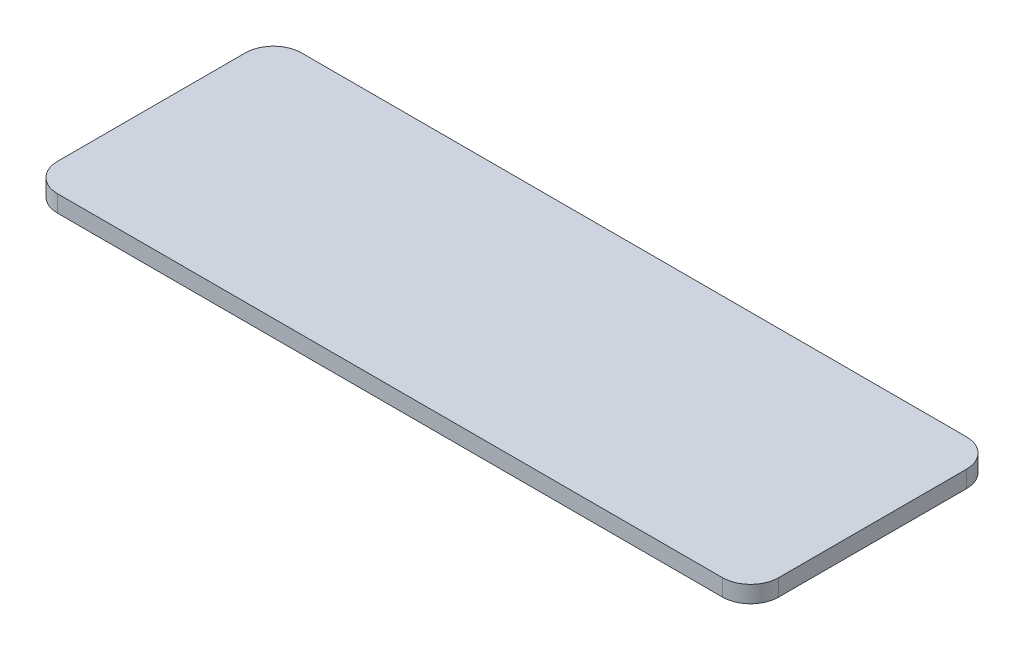
from build123d import *

# Parameters (mm, degrees)
SKETCH2_W           = 256.44751275
SKETCH2_H           = 86.763856324
BOSS_EXTRUDE2_DEPTH = 6
FILLET1_R           = 10


with BuildPart() as part:
    # Sketch2 → Boss-Extrude2 (new body)
    with BuildSketch(Plane(origin=(0, 0, 0), x_dir=(1, 0, 0), z_dir=(0, 1, 0))):
        with Locations((-92.975357556, 78.4180884)):
            Rectangle(SKETCH2_W, SKETCH2_H)
    extrude(amount=BOSS_EXTRUDE2_DEPTH)

    # Fillet1
    fillet1_edges = [part.edges().sort_by_distance(p)[0] for p in [
        (35.248398819, 3, -35.036160238),
        (-221.199113931, 3, -35.036160238),
        (-221.199113931, 3, -121.800016562),
        (35.248398819, 3, -121.800016562),
    ]]
    fillet(fillet1_edges, radius=FILLET1_R)


solid = part.part
